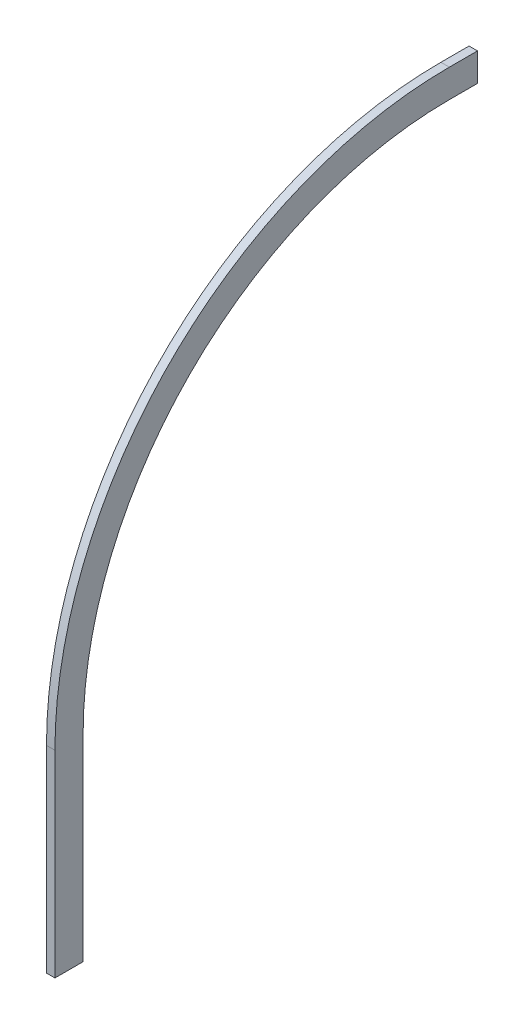
from build123d import *

# Parameters (mm, degrees)
BOSS_EXTRUDE1_DEPTH = 3


with BuildPart() as part:
    # Sketch2 → Boss-Extrude1 (new body)
    with BuildSketch(Plane(origin=(0, 0, 0), x_dir=(0, 0, -1), z_dir=(1, 0, 0))):
        with BuildLine():
            Line((-10, 0), (-10, 70))
            ThreePointArc((-10, 70), (31.005050634, 168.994949366), (130, 210))
            Line((130, 210), (140, 210))
            Line((140, 210), (140, 200))
            Line((140, 200), (130, 200))
            ThreePointArc((130, 200), (38.076118446, 161.923881554), (0, 70))
            Line((0, 70), (0, 0))
            Line((0, 0), (-10, 0))
        make_face()
    extrude(amount=BOSS_EXTRUDE1_DEPTH)


solid = part.part
